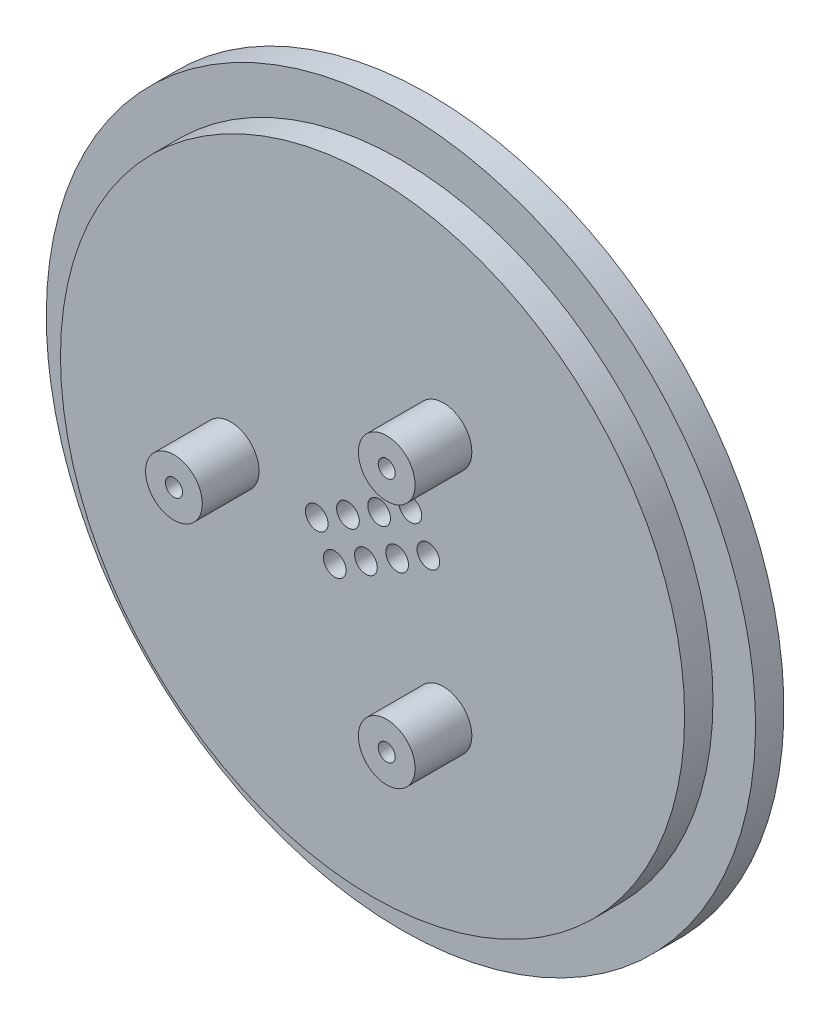
from build123d import *

# Parameters (mm, degrees)
SKETCH_1_R          = 22
EXTRUDE_1_DEPTH     = 2
SKETCH_2_R          = 2
SKETCH_2_R_2        = 0.6
EXTRUDE_2_DEPTH     = 4
SKETCH_3_R          = 25
EXTRUDE_3_DEPTH     = 2
CUT_EXTRUDE_2_DEPTH = 1
SKETCH_6_R          = 5.45
SKETCH_6_R_2        = 3.85
CUT_EXTRUDE_3_DEPTH = 1.3
SKETCH_8_R          = 0.6
CUT_EXTRUDE_4_DEPTH = 18.5
SKETCH_9_R          = 16.695755265
CUT_EXTRUDE_5_DEPTH = 2
SKETCH_10_R         = 1.6
CUT_EXTRUDE_6_DEPTH = 1
SKETCH_11_R         = 1.6
CUT_EXTRUDE_7_DEPTH = 3
SKETCH_13_R         = 2
SKETCH_13_R_2       = 0.6
EXTRUDE_4_DEPTH     = 2
SKETCH_14_R         = 0.8
CUT_EXTRUDE_8_DEPTH = 10


with BuildPart() as part:
    # 草图1 → 凸台-拉伸1 (new body)
    with BuildSketch(Plane.XY):
        Circle(SKETCH_1_R)
    extrude(amount=EXTRUDE_1_DEPTH)

    # 草图2 → 凸台-拉伸2 (add)
    with BuildSketch(Plane.XY.offset(2)):
        with Locations((-10, 0)):
            Circle(SKETCH_2_R)
        with Locations((-10, 0)):
            Circle(SKETCH_2_R_2, mode=Mode.SUBTRACT)
        with Locations((5, 8.660254038)):
            Circle(SKETCH_2_R)
        with Locations((5, 8.660254038)):
            Circle(SKETCH_2_R_2, mode=Mode.SUBTRACT)
        with Locations((5, -8.660254038)):
            Circle(SKETCH_2_R)
        with Locations((5, -8.660254038)):
            Circle(SKETCH_2_R_2, mode=Mode.SUBTRACT)
    extrude(amount=EXTRUDE_2_DEPTH)

    # 草图3 → 凸台-拉伸3 (add)
    with BuildSketch(Plane(origin=(0, 0, 0), x_dir=(-1, 0, 0), z_dir=(0, 0, -1))):
        Circle(SKETCH_3_R)
    extrude(amount=EXTRUDE_3_DEPTH)

    # 草图5 → 切除-拉伸2 (cut)
    with BuildSketch(Plane(origin=(0, 0, -2), x_dir=(-1, 0, 0), z_dir=(0, 0, -1))):
        Polygon((21, -3.95), (21, -4), (29.149006969, -4), (29.149006969, 4), (21, 4), align=None)
    extrude(amount=-CUT_EXTRUDE_2_DEPTH, mode=Mode.SUBTRACT)

    # 草图6 → 切除-拉伸3 (cut)
    with BuildSketch(Plane(origin=(0, 0, -2), x_dir=(-1, 0, 0), z_dir=(0, 0, -1))):
        with Locations((-18, 0)):
            Circle(SKETCH_6_R)
        with Locations((-18, 0)):
            Circle(SKETCH_6_R_2, mode=Mode.SUBTRACT)
        with Locations((9, 15.588457268)):
            Circle(SKETCH_6_R)
        with Locations((9, 15.588457268)):
            Circle(SKETCH_6_R_2, mode=Mode.SUBTRACT)
        with Locations((9, -15.588457268)):
            Circle(SKETCH_6_R)
        with Locations((9, -15.588457268)):
            Circle(SKETCH_6_R_2, mode=Mode.SUBTRACT)
    extrude(amount=-CUT_EXTRUDE_3_DEPTH, mode=Mode.SUBTRACT)

    # 草图8 → 切除-拉伸4 (cut)
    with BuildSketch(Plane.XY.offset(6)):
        with Locations((5, -8.660254038)):
            Circle(SKETCH_8_R)
        with Locations((-10, 0)):
            Circle(SKETCH_8_R)
        with Locations((5, 8.660254038)):
            Circle(SKETCH_8_R)
    extrude(amount=-CUT_EXTRUDE_4_DEPTH, mode=Mode.SUBTRACT)

    # 草图9 → 切除-拉伸5 (cut)
    with BuildSketch(Plane.XY.offset(6)):
        Circle(SKETCH_9_R)
    extrude(amount=-CUT_EXTRUDE_5_DEPTH, mode=Mode.SUBTRACT)

    # 草图10 → 切除-拉伸6 (cut)
    with BuildSketch(Plane(origin=(0, 0, -2), x_dir=(-1, 0, 0), z_dir=(0, 0, -1))):
        with Locations((-5, -8.660254038)):
            Circle(SKETCH_10_R)
        with Locations((-5, 8.660254038)):
            Circle(SKETCH_10_R)
    extrude(amount=-CUT_EXTRUDE_6_DEPTH, mode=Mode.SUBTRACT)

    # 草图11 → 切除-拉伸7 (cut)
    with BuildSketch(Plane(origin=(0, 0, -2), x_dir=(-1, 0, 0), z_dir=(0, 0, -1))):
        with Locations((10, 0)):
            Circle(SKETCH_11_R)
    extrude(amount=-CUT_EXTRUDE_7_DEPTH, mode=Mode.SUBTRACT)

    # 草图13 → 凸台-拉伸4 (add)
    with BuildSketch(Plane.XY.offset(4)):
        with Locations((-10, 0)):
            Circle(SKETCH_13_R)
        with Locations((-10, 0)):
            Circle(SKETCH_13_R_2, mode=Mode.SUBTRACT)
        with Locations((5, 8.660254038)):
            Circle(SKETCH_13_R)
        with Locations((5, 8.660254038)):
            Circle(SKETCH_13_R_2, mode=Mode.SUBTRACT)
        with Locations((5, -8.660254038)):
            Circle(SKETCH_13_R)
        with Locations((5, -8.660254038)):
            Circle(SKETCH_13_R_2, mode=Mode.SUBTRACT)
    extrude(amount=EXTRUDE_4_DEPTH)

    # 草图14 → 切除-拉伸8 (cut)
    with BuildSketch(Plane(origin=(0, 0, -2), x_dir=(-1, 0, 0), z_dir=(0, 0, -1))):
        with Locations((-2.664556788, 3.004852263)):
            Circle(SKETCH_14_R)
        with Locations((-0.464852263, 1.734852263)):
            Circle(SKETCH_14_R)
        with Locations((1.734852263, 0.464852263)):
            Circle(SKETCH_14_R)
        with Locations((3.934556788, -0.805147737)):
            Circle(SKETCH_14_R)
        with Locations((-1.734852263, -0.464852263)):
            Circle(SKETCH_14_R)
        with Locations((0.464852263, -1.734852263)):
            Circle(SKETCH_14_R)
        with Locations((2.664556788, -3.004852263)):
            Circle(SKETCH_14_R)
        with Locations((-3.934556788, 0.805147737)):
            Circle(SKETCH_14_R)
    extrude(amount=-CUT_EXTRUDE_8_DEPTH, mode=Mode.SUBTRACT)


solid = part.part
